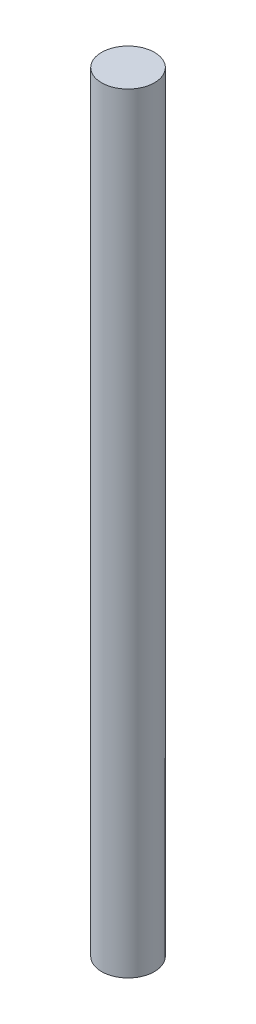
from build123d import *

# Parameters (mm, degrees)
SKETCH1_W = 60
SKETCH1_H = 1750


with BuildPart() as part:
    # Sketch1 → Revolve-Thin3 (revolve)
    with BuildSketch(Plane(origin=(0, 0, 0), x_dir=(0, 0, -1), z_dir=(1, 0, 0))):
        with Locations((30, -875)):
            Rectangle(SKETCH1_W, SKETCH1_H)
    revolve(axis=Axis((0, -1750, 0), (0, 1, 0)))


solid = part.part
